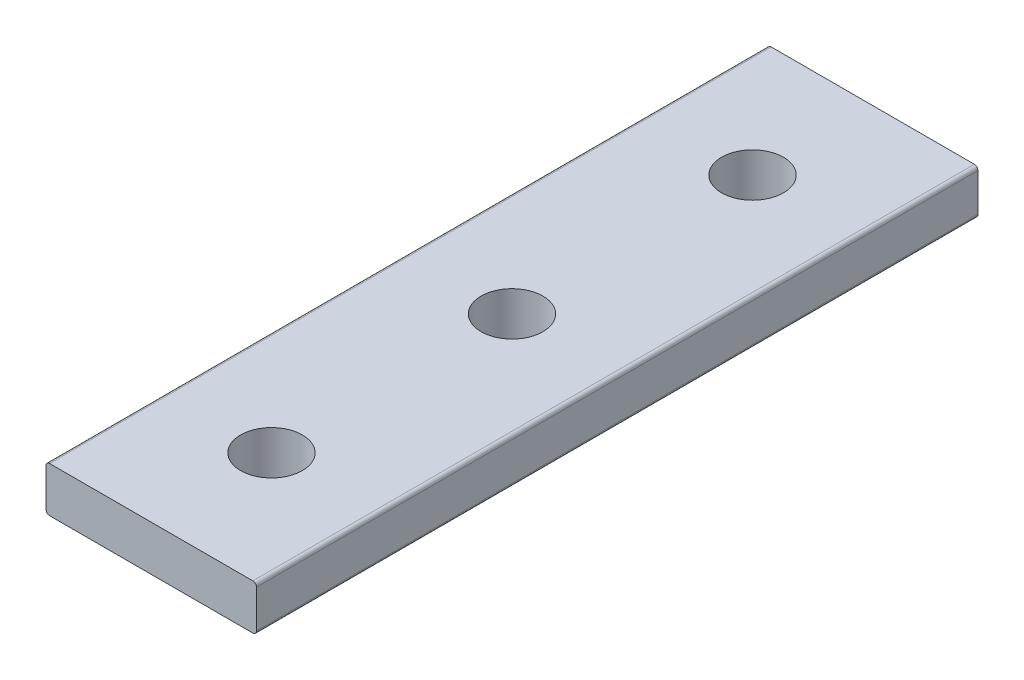
from build123d import *

# Parameters (mm, degrees)
SKETCH1_W                = 22.225
SKETCH1_H                = 76.2
BOSS_EXTRUDE1_DEPTH      = 4.7752
F_0_257_DIAMETER_HOLE1_D = 6.5278
FILLET1_R                = 0.381


with BuildPart() as part:
    # Sketch1 → Boss-Extrude1 (new body)
    with BuildSketch(Plane(origin=(0, 4.7752, 0), x_dir=(1, 0, 0), z_dir=(0, 1, 0))):
        with Locations((11.1125, -38.1)):
            Rectangle(SKETCH1_W, SKETCH1_H)
    extrude(amount=-BOSS_EXTRUDE1_DEPTH)

    # F (0.257) Diameter Hole1 (through all)
    with Locations(Plane(origin=(0, 0, 0), x_dir=(-1, 0, 0), z_dir=(0, -1, 0))):
        with Locations((-11.1125, -12.7), (-11.1125, -38.1), (-11.1125, -63.5)):
            Hole(F_0_257_DIAMETER_HOLE1_D / 2)

    # Fillet1
    fillet1_edges = [part.edges().sort_by_distance(p)[0] for p in [
        (0, 0, 38.1),
        (22.225, 0, 38.1),
        (0, 4.7752, 38.1),
        (22.225, 4.7752, 38.1),
    ]]
    fillet(fillet1_edges, radius=FILLET1_R)


solid = part.part
